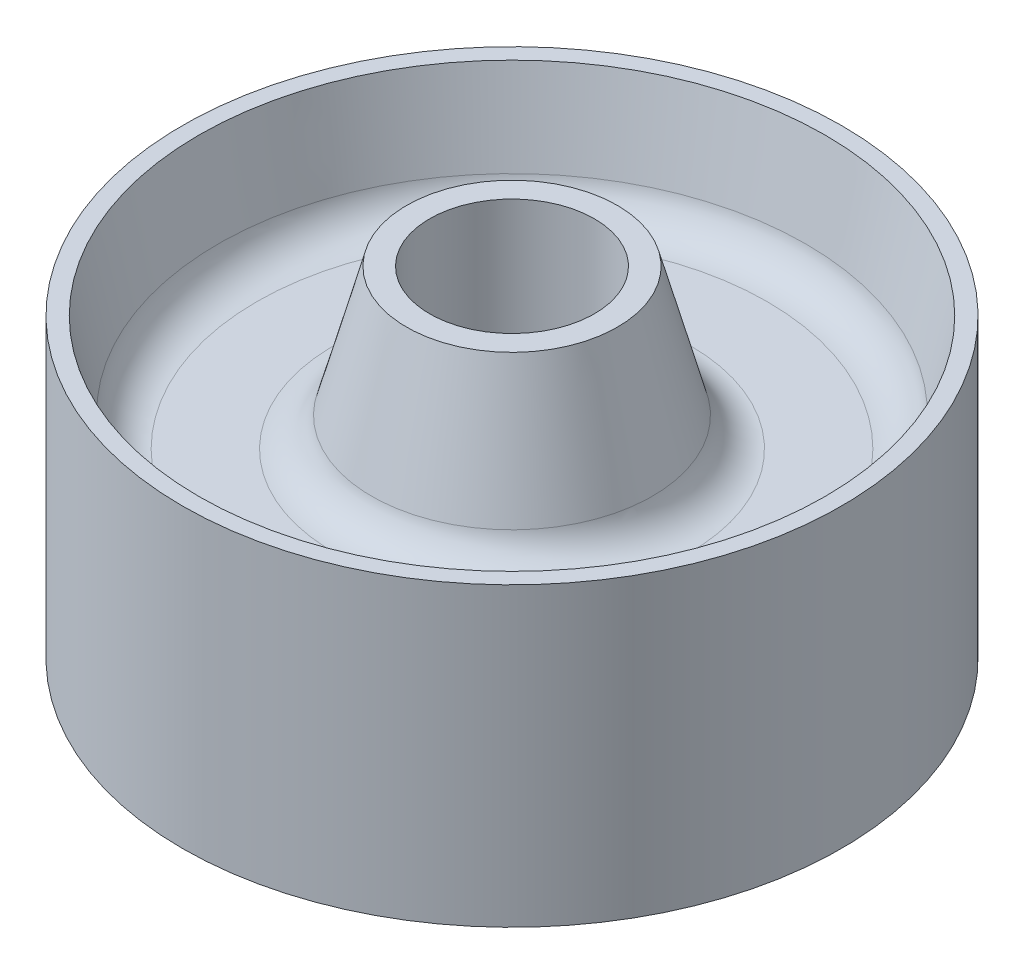
from build123d import *


with BuildPart() as part:
    # Sketch1 → Revolve1 (revolve)
    with BuildSketch(Plane.XY):
        with BuildLine():
            Line((12.5, 0), (16, 0))
            Line((16, 0), (21.299800148, 19.568492854))
            ThreePointArc((21.299800148, 19.568492854), (23.444993074, 22.765026607), (27.09115838, 24))
            Line((27.09115838, 24), (38.716689233, 24))
            ThreePointArc((38.716689233, 24), (42.456896924, 22.69157185), (44.565840272, 19.336948809))
            Line((44.565840272, 19.336948809), (47.5, 6.5))
            Line((47.5, 6.5), (50, 6.5))
            Line((50, 6.5), (50, 51.5))
            Line((50, 51.5), (47.5, 51.5))
            Line((47.5, 51.5), (44.565840272, 38.663051191))
            ThreePointArc((44.565840272, 38.663051191), (42.456896924, 35.30842815), (38.716689233, 34))
            Line((38.716689233, 34), (27.09115838, 34))
            ThreePointArc((27.09115838, 34), (23.444993074, 35.234973393), (21.299800148, 38.431507146))
            Line((21.299800148, 38.431507146), (16, 58))
            Line((16, 58), (12.5, 58))
            Line((12.5, 58), (12.5, 0))
        make_face()
    revolve(axis=Axis((0, 0, 0), (0, 1, 0)))


solid = part.part
